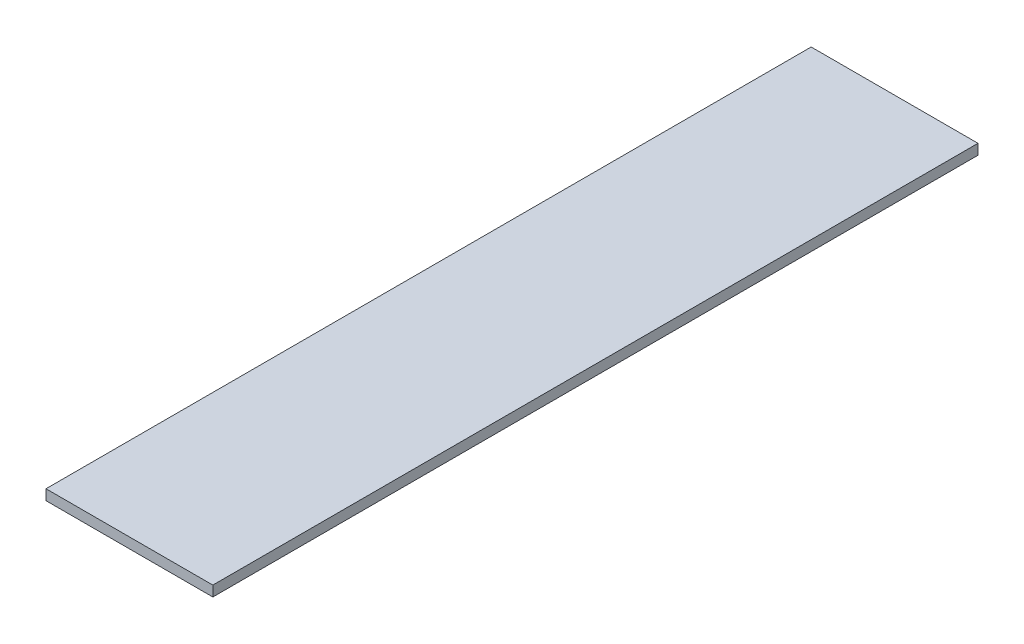
from build123d import *

# Parameters (mm, degrees)
SKETCH1_W           = 102.3
SKETCH1_H           = 469.2
BOSS_EXTRUDE1_DEPTH = 6.35


with BuildPart() as part:
    # Sketch1 → Boss-Extrude1 (new body)
    with BuildSketch(Plane(origin=(0, 0, 0), x_dir=(1, 0, 0), z_dir=(0, 1, 0))):
        with Locations((51.15, 234.6)):
            Rectangle(SKETCH1_W, SKETCH1_H)
    extrude(amount=BOSS_EXTRUDE1_DEPTH)


solid = part.part
